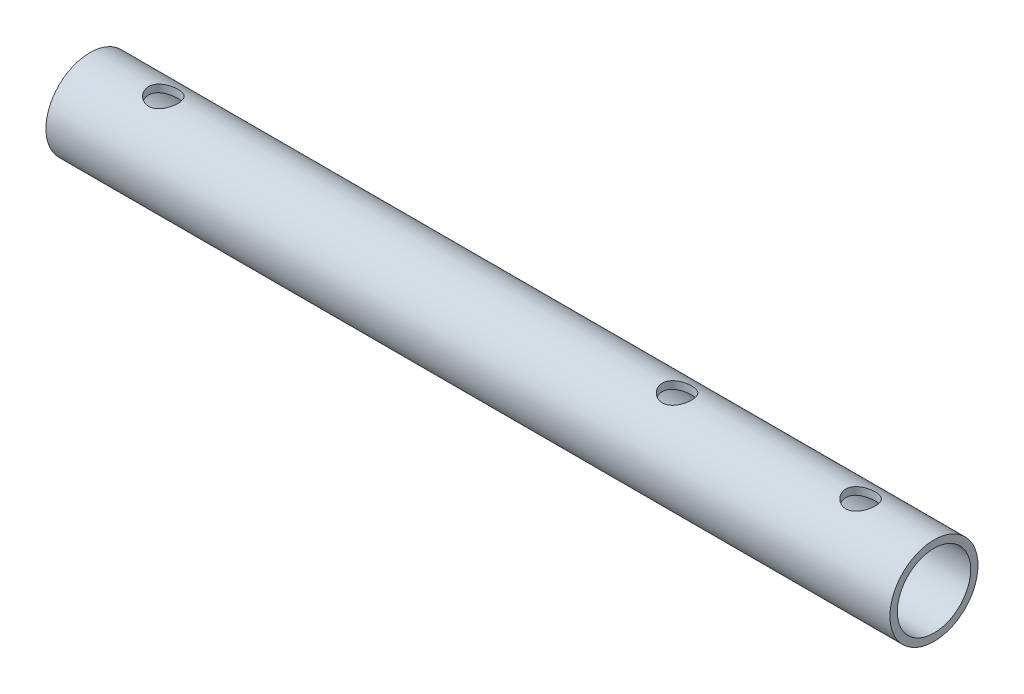
from build123d import *

# Parameters (mm, degrees)
SKETCH1_R           = 6
SKETCH1_R_2         = 5
BOSS_EXTRUDE1_DEPTH = 45
SKETCH3_R           = 6
SKETCH3_R_2         = 5
BOSS_EXTRUDE2_DEPTH = 25
SKETCH2_R           = 2
CUT_EXTRUDE1_DEPTH  = 10


with BuildPart() as part:
    # Sketch1 → Boss-Extrude1 (new body, symmetric)
    with BuildSketch(Plane(origin=(0, 0, 0), x_dir=(0, 0, -1), z_dir=(1, 0, 0))):
        Circle(SKETCH1_R)
        Circle(SKETCH1_R_2, mode=Mode.SUBTRACT)
    extrude(amount=BOSS_EXTRUDE1_DEPTH, both=True)

    # Sketch3 → Boss-Extrude2 (add)
    with BuildSketch(Plane(origin=(45, 0, 0), x_dir=(0, 0, -1), z_dir=(1, 0, 0))):
        Circle(SKETCH3_R)
        Circle(SKETCH3_R_2, mode=Mode.SUBTRACT)
    extrude(amount=BOSS_EXTRUDE2_DEPTH)

    # Sketch2 → Cut-Extrude1 (cut, symmetric)
    with BuildSketch(Plane(origin=(0, 0, 0), x_dir=(1, 0, 0), z_dir=(0, 1, 0))):
        with Locations((-35, 0)):
            Circle(SKETCH2_R)
        with Locations((35, 0)):
            Circle(SKETCH2_R)
        with Locations((60, 0)):
            Circle(SKETCH2_R)
    extrude(amount=CUT_EXTRUDE1_DEPTH, both=True, mode=Mode.SUBTRACT)


solid = part.part
